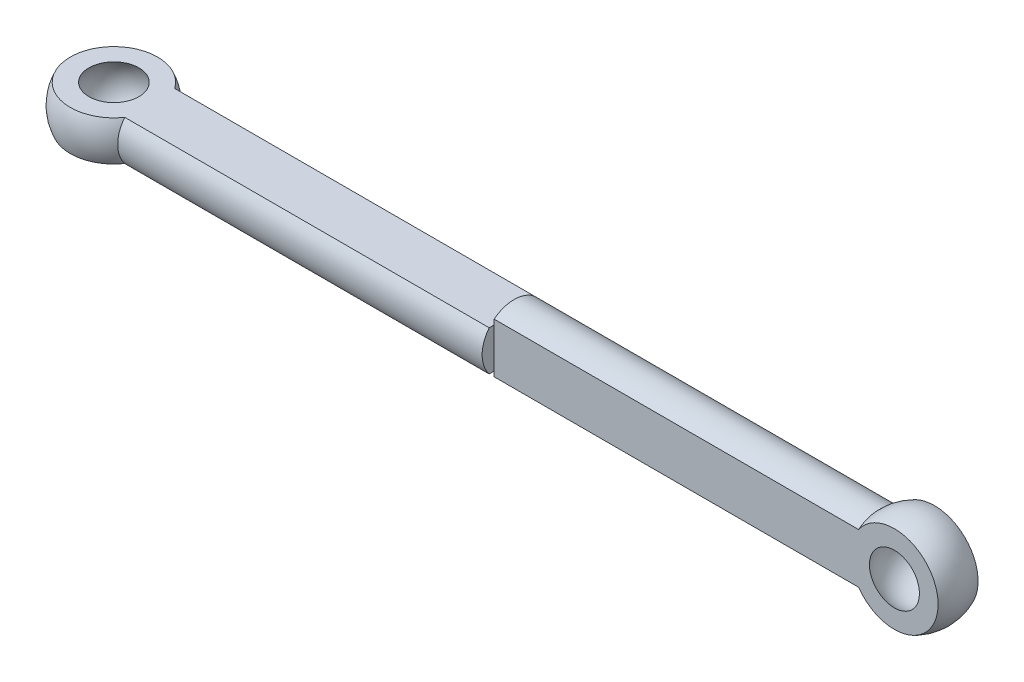
from build123d import *

# Parameters (mm, degrees)
SKETCH3_OUTSIDE_W   = 19.328
SKETCH3_OUTSIDE_H   = 19.328
SKETCH3_OUTSIDE_W_2 = 6
SKETCH3_OUTSIDE_H_2 = 2.5
CUT_EXTRUDE2_DEPTH  = 60
SKETCH5_OUTSIDE_W   = 19.328
SKETCH5_OUTSIDE_H   = 19.328
SKETCH5_OUTSIDE_W_2 = 2.5
SKETCH5_OUTSIDE_H_2 = 6
CUT_EXTRUDE3_DEPTH  = 29


with BuildPart() as part:
    # Sketch2 → Revolve1 (revolve)
    with BuildSketch(Plane(origin=(0, 0, 0), x_dir=(1, 0, 0), z_dir=(0, 1, 0))):
        with BuildLine():
            Line((-27, 0), (-28, 0))
            ThreePointArc((-28, 0), (-26.070466269, -2.802517077), (-22.763932023, -2))
            Line((-22.763932023, -2), (0, -2))
            Line((0, -2), (0, 0))
            Line((0, 0), (-23, 0))
            ThreePointArc((-23, 0), (-25, -2), (-27, 0))
        make_face()
        with BuildLine():
            Line((0, 0), (0, -2))
            Line((0, -2), (22.763932023, -2))
            ThreePointArc((22.763932023, -2), (26.070466269, -2.802517077), (28, 0))
            Line((28, 0), (27, 0))
            ThreePointArc((27, 0), (25, -2), (23, 0))
            Line((23, 0), (0, 0))
        make_face()
    revolve(axis=Axis((0, 0, 0), (-1, 0, 0)))

    # Sketch3 outside → Cut-Extrude2 (cut)
    with BuildSketch(Plane(origin=(0, 0, 0), x_dir=(0, 0, -1), z_dir=(1, 0, 0))):
        Rectangle(SKETCH3_OUTSIDE_W, SKETCH3_OUTSIDE_H)
        Rectangle(SKETCH3_OUTSIDE_W_2, SKETCH3_OUTSIDE_H_2, mode=Mode.SUBTRACT)
    extrude(amount=-CUT_EXTRUDE2_DEPTH, mode=Mode.SUBTRACT)

    # Sketch5 outside → Cut-Extrude3 (cut, through all)
    with BuildSketch(Plane(origin=(0, 0, 0), x_dir=(0, 0, -1), z_dir=(1, 0, 0))):
        Rectangle(SKETCH5_OUTSIDE_W, SKETCH5_OUTSIDE_H)
        Rectangle(SKETCH5_OUTSIDE_W_2, SKETCH5_OUTSIDE_H_2, mode=Mode.SUBTRACT)
    extrude(amount=CUT_EXTRUDE3_DEPTH, mode=Mode.SUBTRACT)


solid = part.part
